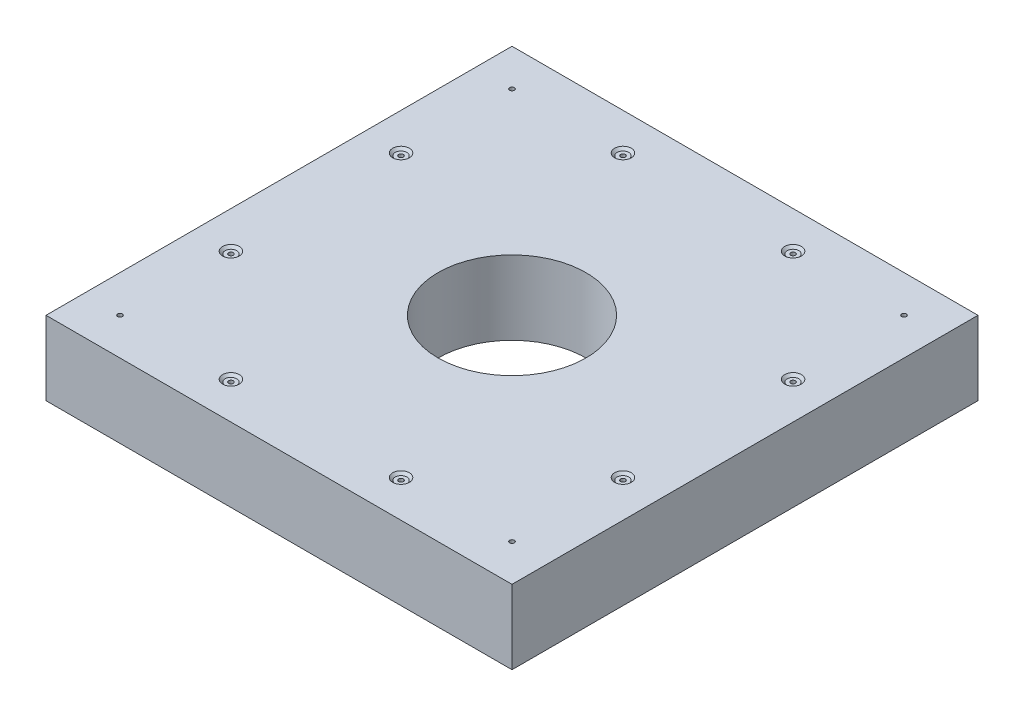
from build123d import *

# Parameters (mm, degrees)
SKETCH1_W                                   = 160
SKETCH1_H                                   = 160
BOSS_EXTRUDE1_DEPTH                         = 25.4
CBORE_FOR_0_BINDING_HEAD_MACHINE_SC_2_COUNT = 2
CBORE_FOR_0_BINDING_HEAD_MACHINE_SC_2_PITCH = 134.6
CBORE_FOR_0_BINDING_HEAD_MACHINE_SC_3_COUNT = 2
CBORE_FOR_0_BINDING_HEAD_MACHINE_SC_3_PITCH = 190.353145495
CBORE_FOR_0_BINDING_HEAD_MACHINE_SC_4_COUNT = 2
CBORE_FOR_0_BINDING_HEAD_MACHINE_SC_4_PITCH = 134.6
CBORE_FOR_0_BINDING_HEAD_MACHINE_SC_5_COUNT = 2
CBORE_FOR_0_BINDING_HEAD_MACHINE_SC_5_PITCH = 58.400000007
CIRPATTERN1_COUNT                           = 4
SKETCH6_R                                   = 25.4
CUT_EXTRUDE1_DEPTH                          = 116.953266448


with BuildPart() as part:
    # Sketch1 → Boss-Extrude1 (new body)
    with BuildSketch(Plane(origin=(0, 0, 0), x_dir=(1, 0, 0), z_dir=(0, 1, 0))):
        Rectangle(SKETCH1_W, SKETCH1_H)
    extrude(amount=BOSS_EXTRUDE1_DEPTH)

    # Sketch3 → CBORE for _0 Binding Head Machine Screw1 (revolve, cut)
    with BuildSketch(Plane(origin=(-67.3, 0, -67.3), x_dir=(0, 0, -1), z_dir=(1, 0, 0))):
        Polygon((0, 0), (0, 25.4), (0.80645, 25.4), (0.80645, 0.8128), (1.98501, 0.8128), (1.98501, 0.87249), (2.8575, 0), align=None)
    cbore_for_0_binding_head_machine_screw1 = revolve(axis=Axis((-67.3, -6.35, -67.3), (0, 1, 0)), mode=Mode.SUBTRACT)

    # CBORE for _0 Binding Head Machine Sc 2: CBORE for _0 Binding Head Machine Screw1 ×2
    with Locations(*[(i * CBORE_FOR_0_BINDING_HEAD_MACHINE_SC_2_PITCH, 0, 0) for i in range(1, CBORE_FOR_0_BINDING_HEAD_MACHINE_SC_2_COUNT)]):
        add(cbore_for_0_binding_head_machine_screw1, mode=Mode.SUBTRACT)

    # CBORE for _0 Binding Head Machine Sc 3: CBORE for _0 Binding Head Machine Screw1 ×2
    with Locations(*[Vector(0.7071067811865475, 0, 0.7071067811865476) * (i * CBORE_FOR_0_BINDING_HEAD_MACHINE_SC_3_PITCH) for i in range(1, CBORE_FOR_0_BINDING_HEAD_MACHINE_SC_3_COUNT)]):
        add(cbore_for_0_binding_head_machine_screw1, mode=Mode.SUBTRACT)

    # CBORE for _0 Binding Head Machine Sc 4: CBORE for _0 Binding Head Machine Screw1 ×2
    with Locations(*[(0, 0, i * CBORE_FOR_0_BINDING_HEAD_MACHINE_SC_4_PITCH) for i in range(1, CBORE_FOR_0_BINDING_HEAD_MACHINE_SC_4_COUNT)]):
        add(cbore_for_0_binding_head_machine_screw1, mode=Mode.SUBTRACT)

    # Sketch5 → CBORE for _0 Binding Head Machine Screw2 (revolve, cut)
    with BuildSketch(Plane(origin=(-67.300526968, 25.4, -29.200000004), x_dir=(0, 0, 1), z_dir=(1, 0, 0))):
        Polygon((0, 0), (0, 25.4), (0.80645, 25.4), (0.80645, 0.8128), (1.98501, 0.8128), (1.98501, 0.87249), (2.8575, 0), align=None)
    cbore_for_0_binding_head_machine_screw2 = revolve(axis=Axis((-67.300526968, 31.75, -29.200000004), (0, -1, 0)), mode=Mode.SUBTRACT)

    # CBORE for _0 Binding Head Machine Sc 5: CBORE for _0 Binding Head Machine Screw2 ×2
    with Locations(*[(0, 0, i * CBORE_FOR_0_BINDING_HEAD_MACHINE_SC_5_PITCH) for i in range(1, CBORE_FOR_0_BINDING_HEAD_MACHINE_SC_5_COUNT)]):
        add(cbore_for_0_binding_head_machine_screw2, mode=Mode.SUBTRACT)

    # CirPattern1: CBORE for _0 Binding Head Machine Screw2 ×4 about axis
    cirpattern1_axis = Axis((0, 26.67, 0), (0, -1, 0))
    for i in range(1, CIRPATTERN1_COUNT):
        add(cbore_for_0_binding_head_machine_screw2.rotate(cirpattern1_axis, i * 360 / CIRPATTERN1_COUNT), mode=Mode.SUBTRACT)

    # CirPattern1 copy 1 sketch → CirPattern1 copy 1 (revolve, cut)
    with BuildSketch(Plane(origin=(-29.200000004, 25.4, -67.300526968), x_dir=(-1, 0, 0), z_dir=(0, 0, 1))):
        Polygon((0, 0), (0, 25.4), (0.80645, 25.4), (0.80645, 0.8128), (1.98501, 0.8128), (1.98501, 0.87249), (2.8575, 0), align=None)
    revolve(axis=Axis((-29.200000004, 31.75, -67.300526968), (0, -1, 0)), mode=Mode.SUBTRACT)

    # CirPattern1 copy 2 sketch → CirPattern1 copy 2 (revolve, cut)
    with BuildSketch(Plane(origin=(67.300526968, 25.4, -29.200000004), x_dir=(0, 0, -1), z_dir=(-1, 0, 0))):
        Polygon((0, 0), (0, 25.4), (0.80645, 25.4), (0.80645, 0.8128), (1.98501, 0.8128), (1.98501, 0.87249), (2.8575, 0), align=None)
    revolve(axis=Axis((67.300526968, 31.75, -29.200000004), (0, -1, 0)), mode=Mode.SUBTRACT)

    # CirPattern1 copy 3 sketch → CirPattern1 copy 3 (revolve, cut)
    with BuildSketch(Plane(origin=(29.200000004, 25.4, 67.300526968), x_dir=(1, 0, 0), z_dir=(0, 0, -1))):
        Polygon((0, 0), (0, 25.4), (0.80645, 25.4), (0.80645, 0.8128), (1.98501, 0.8128), (1.98501, 0.87249), (2.8575, 0), align=None)
    revolve(axis=Axis((29.200000004, 31.75, 67.300526968), (0, -1, 0)), mode=Mode.SUBTRACT)

    # Sketch6 → Cut-Extrude1 (cut, through all)
    with BuildSketch(Plane(origin=(0, 25.4, 0), x_dir=(1, 0, 0), z_dir=(0, 1, 0))):
        Circle(SKETCH6_R)
    extrude(amount=-CUT_EXTRUDE1_DEPTH, mode=Mode.SUBTRACT)


solid = part.part
